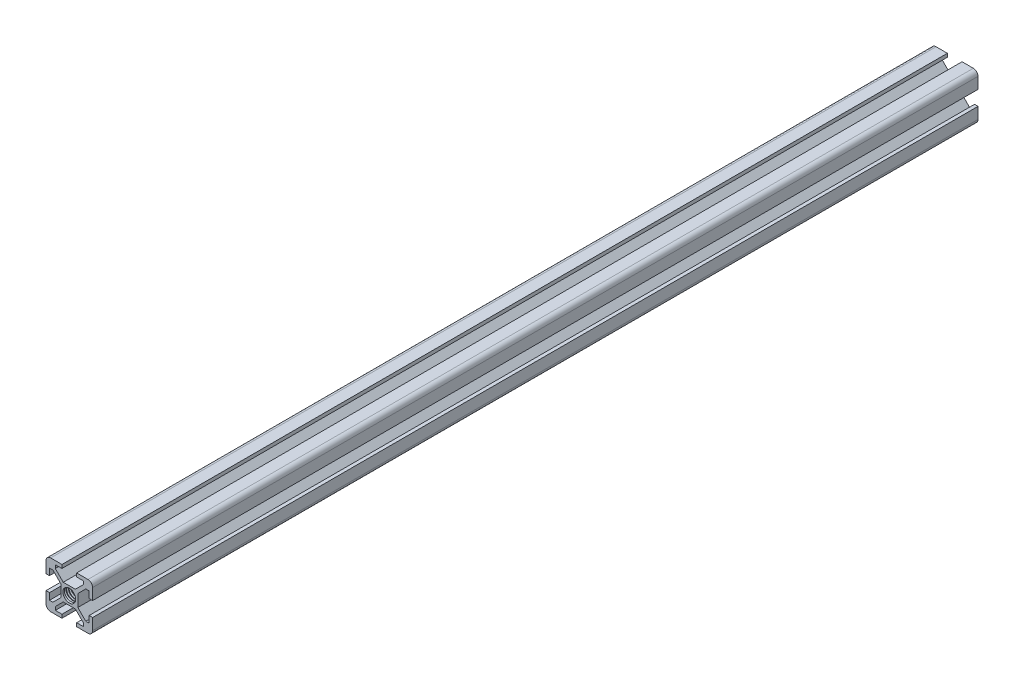
from build123d import *

# Parameters (mm, degrees)
SKETCH1_R           = 2.75
BOSS_EXTRUDE1_DEPTH = 380
CUT_SWEEP2_PITCH    = 1
CUT_SWEEP2_HEIGHT   = 18.5
CUT_SWEEP2_RADIUS   = 2.15


with BuildPart() as part:
    # Sketch1 → Boss-Extrude1 (new body)
    with BuildSketch(Plane.XY):
        with BuildLine():
            Line((-2.599339828, -3.66), (2.599339828, -3.66))
            Line((2.599339828, -3.66), (5.995, -7.055660172))
            Line((5.995, -7.055660172), (5.995, -8.5))
            Line((5.995, -8.5), (3.15, -8.5))
            Line((3.15, -8.5), (3.15, -10))
            Line((3.15, -10), (8, -10))
            ThreePointArc((8, -10), (9.414213562, -9.414213562), (10, -8))
            Line((10, -8), (10, -3.15))
            Line((10, -3.15), (8.5, -3.15))
            Line((8.5, -3.15), (8.5, -5.995))
            Line((8.5, -5.995), (7.055660172, -5.995))
            Line((7.055660172, -5.995), (3.66, -2.599339828))
            Line((3.66, -2.599339828), (3.66, 2.599339828))
            Line((3.66, 2.599339828), (7.055660172, 5.995))
            Line((7.055660172, 5.995), (8.5, 5.995))
            Line((8.5, 5.995), (8.5, 3.15))
            Line((8.5, 3.15), (10, 3.15))
            Line((10, 3.15), (10, 8))
            ThreePointArc((10, 8), (9.414213562, 9.414213562), (8, 10))
            Line((8, 10), (3.15, 10))
            Line((3.15, 10), (3.15, 8.5))
            Line((3.15, 8.5), (5.995, 8.5))
            Line((5.995, 8.5), (5.995, 7.055660172))
            Line((5.995, 7.055660172), (2.599339828, 3.66))
            Line((2.599339828, 3.66), (-2.599339828, 3.66))
            Line((-2.599339828, 3.66), (-5.995, 7.055660172))
            Line((-5.995, 7.055660172), (-5.995, 8.5))
            Line((-5.995, 8.5), (-3.15, 8.5))
            Line((-3.15, 8.5), (-3.15, 10))
            Line((-3.15, 10), (-8, 10))
            ThreePointArc((-8, 10), (-9.414213562, 9.414213562), (-10, 8))
            Line((-10, 8), (-10, 3.15))
            Line((-10, 3.15), (-8.5, 3.15))
            Line((-8.5, 3.15), (-8.5, 5.995))
            Line((-8.5, 5.995), (-7.055660172, 5.995))
            Line((-7.055660172, 5.995), (-3.66, 2.599339828))
            Line((-3.66, 2.599339828), (-3.66, -2.599339828))
            Line((-3.66, -2.599339828), (-7.055660172, -5.995))
            Line((-7.055660172, -5.995), (-8.5, -5.995))
            Line((-8.5, -5.995), (-8.5, -3.15))
            Line((-8.5, -3.15), (-10, -3.15))
            Line((-10, -3.15), (-10, -8))
            ThreePointArc((-10, -8), (-9.414213562, -9.414213562), (-8, -10))
            Line((-8, -10), (-3.15, -10))
            Line((-3.15, -10), (-3.15, -8.5))
            Line((-3.15, -8.5), (-5.995, -8.5))
            Line((-5.995, -8.5), (-5.995, -7.055660172))
            Line((-5.995, -7.055660172), (-2.599339828, -3.66))
        make_face()
        Circle(SKETCH1_R, mode=Mode.SUBTRACT)
    extrude(amount=BOSS_EXTRUDE1_DEPTH)

    # Cut-Sweep2: sweep along a helix
    with BuildLine() as cut_sweep2_path:
        Helix(CUT_SWEEP2_PITCH, CUT_SWEEP2_HEIGHT, CUT_SWEEP2_RADIUS, center=(0, 0, 1.2), direction=(0, 0, 1))
    # Sketch3 → Cut-Sweep2 (sweep, cut)
    with BuildSketch(Plane(origin=(0, 0, 0), x_dir=(0, 0, -1), z_dir=(1, 0, 0))):
        Polygon((-0.75, 3.389519053), (-1.125, 2.74), (-0.375, 2.74), align=None)
    cut_sweep2 = sweep(path=cut_sweep2_path.line, is_frenet=True, mode=Mode.SUBTRACT)

    # Mirror1: Cut-Sweep2 across plane
    add(cut_sweep2.mirror(Plane(origin=(0, 0, 190), x_dir=(1, 0, 0), z_dir=(0, 0, -1))), mode=Mode.SUBTRACT)


solid = part.part
